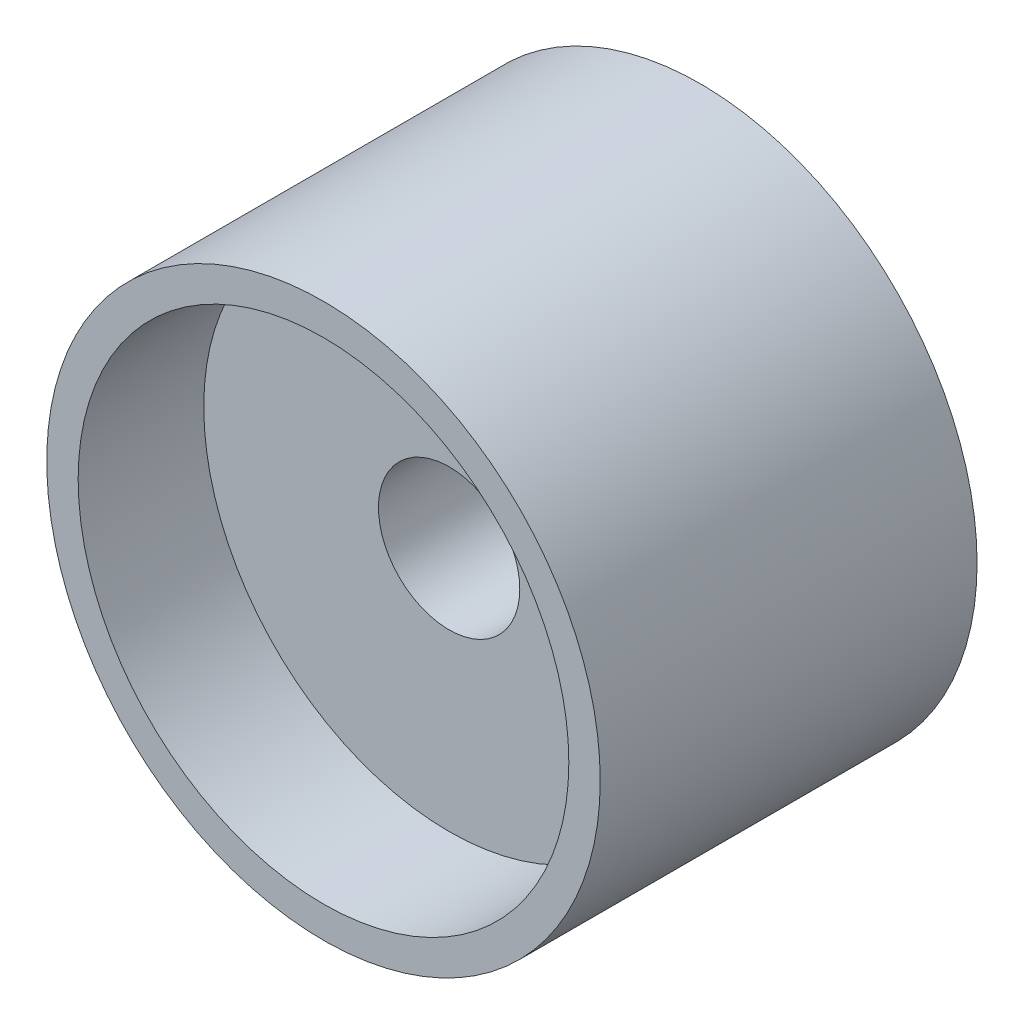
from build123d import *

# Parameters (mm, degrees)
SKETCH1_R                = 4.40625
SKETCH1_R_2              = 3.90625
BOSS_EXTRUDE1_DEPTH      = 3
BOSS_EXTRUDE2_DEPTH      = 1
BOSS_EXTRUDE2_DEPTH_BACK = 3
SKETCH1_3_R              = 4.40625
SKETCH1_3_R_2            = 1.125


with BuildPart() as part:
    # Sketch1 → Boss-Extrude1 (new body)
    with BuildSketch(Plane.XY):
        Circle(SKETCH1_R)
        Circle(SKETCH1_R_2, mode=Mode.SUBTRACT)
    extrude(amount=BOSS_EXTRUDE1_DEPTH)

    # Sketch1_3 → Boss-Extrude2 (add, two sides: drawn at the far end of the back side and taken through both)
    with BuildSketch(Plane.XY.offset(-BOSS_EXTRUDE2_DEPTH_BACK)):
        Circle(SKETCH1_3_R)
        Circle(SKETCH1_3_R_2, mode=Mode.SUBTRACT)
    extrude(amount=BOSS_EXTRUDE2_DEPTH + BOSS_EXTRUDE2_DEPTH_BACK)


solid = part.part
